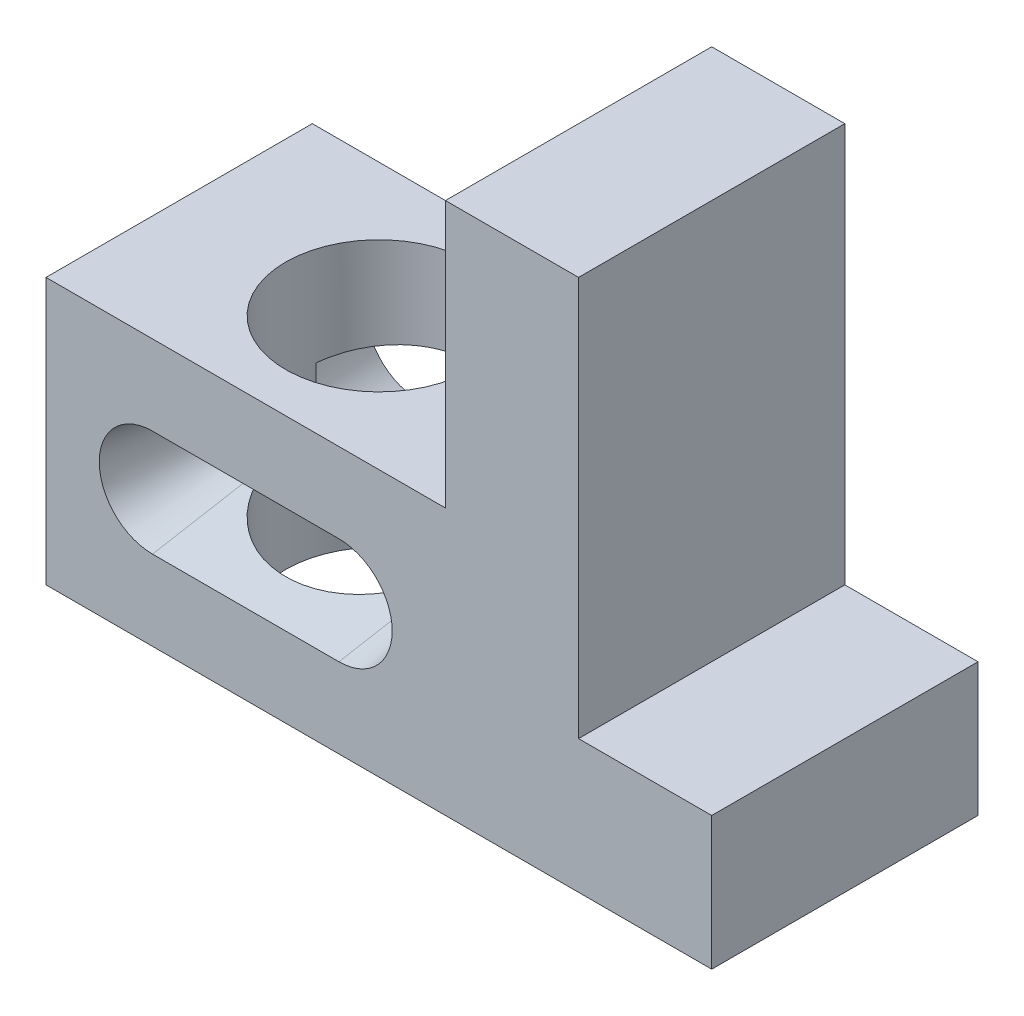
from build123d import *

# Parameters (mm, degrees)
BOSS_EXTRUDE1_DEPTH = 50
CUT_EXTRUDE1_DEPTH  = 20
CUT_EXTRUDE1_TAPER  = 10
CUT_EXTRUDE2_DEPTH  = 20
CUT_EXTRUDE2_TAPER  = 10
SKETCH4_R           = 17.5
CUT_EXTRUDE3_DEPTH  = 60


with BuildPart() as part:
    # Sketch1 → Boss-Extrude1 (new body)
    with BuildSketch(Plane.XY):
        Polygon((-50.731721796, 0), (74.268278204, 0), (74.268278204, 25), (49.268278204, 25), (49.268278204, 100), (24.268278204, 100), (24.268278204, 50), (-50.731721796, 50), align=None)
    extrude(amount=BOSS_EXTRUDE1_DEPTH)

    # Sketch2 → Cut-Extrude1 (cut)
    with BuildSketch(Plane.XY.offset(50)):
        with BuildLine():
            ThreePointArc((-30.731721796, 35), (-40.731721796, 25), (-30.731721796, 15))
            Line((-30.731721796, 15), (4.268278204, 15))
            ThreePointArc((4.268278204, 15), (14.268278204, 25), (4.268278204, 35))
            Line((4.268278204, 35), (-30.731721796, 35))
        make_face()
    extrude(amount=-CUT_EXTRUDE1_DEPTH, taper=CUT_EXTRUDE1_TAPER, mode=Mode.SUBTRACT)

    # Sketch3 → Cut-Extrude2 (cut)
    with BuildSketch(Plane(origin=(0, 0, 0), x_dir=(-1, 0, 0), z_dir=(0, 0, -1))):
        with BuildLine():
            ThreePointArc((-4.268278204, 35), (-14.268278204, 25), (-4.268278204, 15))
            Line((-4.268278204, 15), (30.731721796, 15))
            ThreePointArc((30.731721796, 15), (40.731721796, 25), (30.731721796, 35))
            Line((30.731721796, 35), (-4.268278204, 35))
        make_face()
    extrude(amount=-CUT_EXTRUDE2_DEPTH, taper=CUT_EXTRUDE2_TAPER, mode=Mode.SUBTRACT)

    # Sketch4 → Cut-Extrude3 (cut)
    with BuildSketch(Plane(origin=(0, 50, 0), x_dir=(1, 0, 0), z_dir=(0, 1, 0))):
        with Locations((-13.231721796, -25)):
            Circle(SKETCH4_R)
    extrude(amount=-CUT_EXTRUDE3_DEPTH, mode=Mode.SUBTRACT)


solid = part.part
